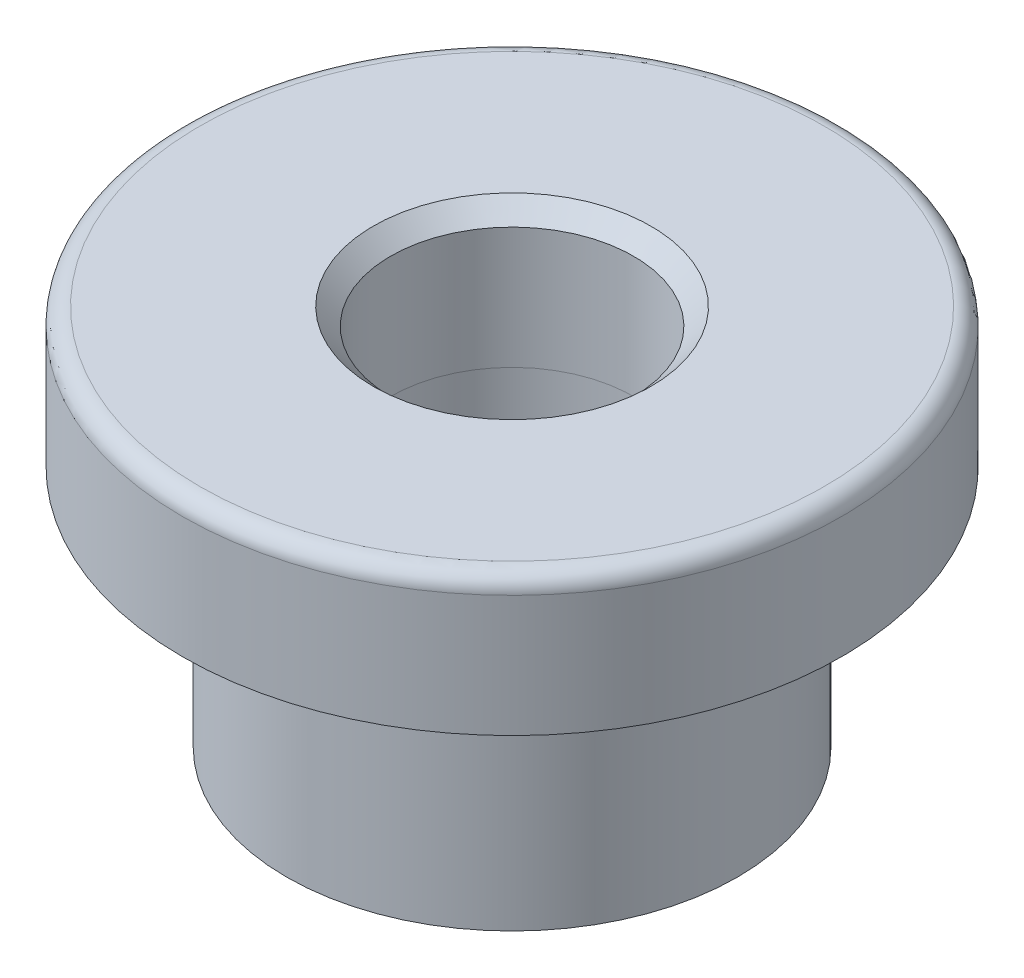
from build123d import *

# Parameters (mm, degrees)
SKETCH1_R           = 6.5
SKETCH1_R_2         = 3.5
BOSS_EXTRUDE1_DEPTH = 7
SKETCH2_R           = 9.5
SKETCH2_R_2         = 3.503174071
BOSS_EXTRUDE3_DEPTH = 4
CHAMFER1_SIZE       = 0.5
FILLET1_R           = 0.5


with BuildPart() as part:
    # Sketch1 → Boss-Extrude1 (new body)
    with BuildSketch(Plane(origin=(0, 0, 0), x_dir=(1, 0, 0), z_dir=(0, 1, 0))):
        with Locations(Location((0, 0, 0), (0, 0, 270))):
            Circle(SKETCH1_R)
        with Locations(Location((0, 0, 0), (0, 0, 270))):
            Circle(SKETCH1_R_2, mode=Mode.SUBTRACT)
    extrude(amount=BOSS_EXTRUDE1_DEPTH)

    # Sketch2 → Boss-Extrude3 (add)
    with BuildSketch(Plane(origin=(0, 7, 0), x_dir=(1, 0, 0), z_dir=(0, 1, 0))):
        with Locations(Location((0, 0, 0), (0, 0, 270))):
            Circle(SKETCH2_R)
        with Locations(Location((0, 0, 0), (0, 0, 270))):
            Circle(SKETCH2_R_2, mode=Mode.SUBTRACT)
    extrude(amount=BOSS_EXTRUDE3_DEPTH)

    # Chamfer1
    chamfer1_edges = [part.edges().sort_by_distance(p)[0] for p in [
        (0, 11, -3.503174071),
    ]]
    chamfer(chamfer1_edges, length=CHAMFER1_SIZE)

    # Fillet1
    fillet1_edges = [part.edges().sort_by_distance(p)[0] for p in [
        (0, 11, -9.5),
    ]]
    fillet(fillet1_edges, radius=FILLET1_R)


solid = part.part
